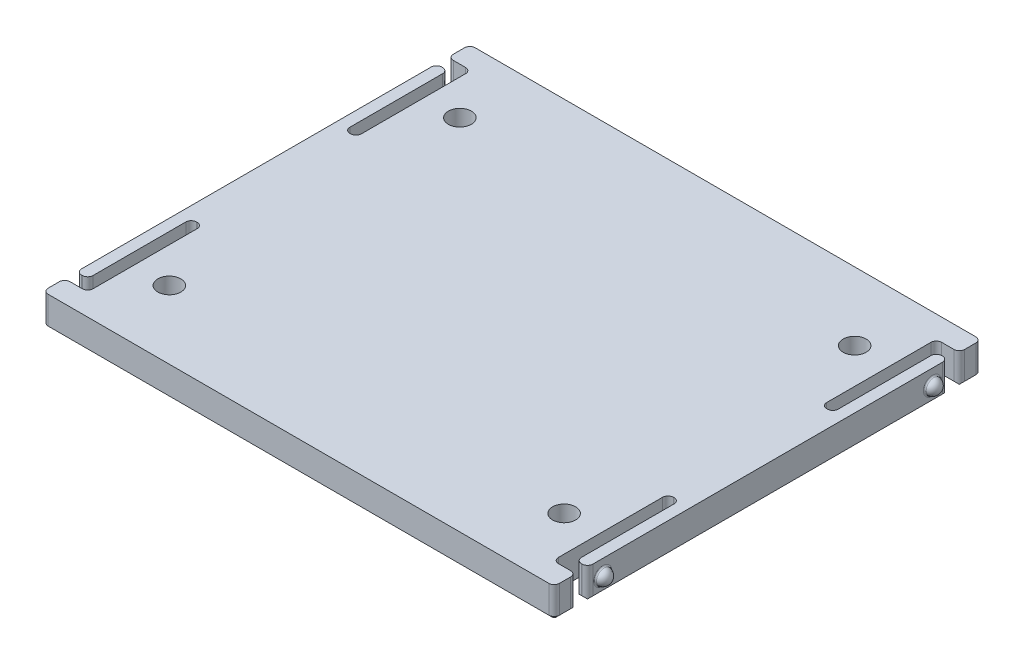
from build123d import *

# Parameters (mm, degrees)
BOSS_EXTRUDE1_DEPTH = 4
SKETCH3_R           = 1.5
CUT_EXTRUDE2_DEPTH  = 5
CHAMFER1_SIZE       = 0.4
FILLET1_R           = 0.7
FILLET2_R           = 0.2


with BuildPart() as part:
    # Sketch1 → Boss-Extrude1 (new body)
    with BuildSketch(Plane(origin=(0, 0, 0), x_dir=(1, 0, 0), z_dir=(0, 1, 0))):
        with BuildLine():
            Line((-33.35, 25), (-30.35, 25))
            Line((-30.35, 25), (-30.35, 10))
            Line((-30.35, 10), (-31.85, 10))
            Line((-31.85, 10), (-31.85, 23.5))
            Line((-31.85, 23.5), (-33.35, 23.5))
            Line((-33.35, 23.5), (-33.35, -23.5))
            Line((-33.35, -23.5), (-31.85, -23.5))
            Line((-31.85, -23.5), (-31.85, -10))
            Line((-31.85, -10), (-30.35, -10))
            Line((-30.35, -10), (-30.35, -25))
            Line((-30.35, -25), (-33.35, -25))
            Line((-33.35, -25), (-33.35, -27.15))
            ThreePointArc((-33.35, -27.15), (-33.144974747, -27.644974747), (-32.65, -27.85))
            Line((-32.65, -27.85), (32.65, -27.85))
            ThreePointArc((32.65, -27.85), (33.144974747, -27.644974747), (33.35, -27.15))
            Line((33.35, -27.15), (33.35, -25))
            Line((33.35, -25), (30.35, -25))
            Line((30.35, -25), (30.35, -10))
            Line((30.35, -10), (31.85, -10))
            Line((31.85, -10), (31.85, -23.5))
            Line((31.85, -23.5), (33.35, -23.5))
            Line((33.35, -23.5), (33.35, 23.5))
            Line((33.35, 23.5), (31.85, 23.5))
            Line((31.85, 23.5), (31.85, 10))
            Line((31.85, 10), (30.35, 10))
            Line((30.35, 10), (30.35, 25))
            Line((30.35, 25), (33.35, 25))
            Line((33.35, 25), (33.35, 27.15))
            ThreePointArc((33.35, 27.15), (33.144974747, 27.644974747), (32.65, 27.85))
            Line((32.65, 27.85), (-32.65, 27.85))
            ThreePointArc((-32.65, 27.85), (-33.144974747, 27.644974747), (-33.35, 27.15))
            Line((-33.35, 27.15), (-33.35, 25))
        make_face()
    extrude(amount=BOSS_EXTRUDE1_DEPTH)

    # Sketch3 → Cut-Extrude2 (cut, through all)
    with BuildSketch(Plane(origin=(0, 4, 0), x_dir=(1, 0, 0), z_dir=(0, 1, 0))):
        with Locations((-25.75, 18.95)):
            Circle(SKETCH3_R)
        with Locations((25.75, 18.95)):
            Circle(SKETCH3_R)
        with Locations((25.75, -18.95)):
            Circle(SKETCH3_R)
        with Locations((-25.75, -18.95)):
            Circle(SKETCH3_R)
    extrude(amount=-CUT_EXTRUDE2_DEPTH, mode=Mode.SUBTRACT)

    # Sketch5 → Revolve1 (revolve)
    with BuildSketch(Plane(origin=(0, 2, 0), x_dir=(1, 0, 0), z_dir=(0, 1, 0))):
        with BuildLine():
            Line((-34.35, 21.5), (-33.35, 21.5))
            Line((-33.35, 21.5), (-33.35, 20.5))
            ThreePointArc((-33.35, 20.5), (-34.057106781, 20.792893219), (-34.35, 21.5))
        make_face()
    revolve1 = revolve(axis=Axis((-34.35, 2, -21.5), (1, 0, 0)))

    # Mirror1: Revolve1 across plane
    add(revolve1.mirror(Plane.XY))

    # Mirror2: Revolve1 across plane
    add(revolve1.mirror(Plane(origin=(0, 0, 0), x_dir=(0, 0, 1), z_dir=(1, 0, 0))))

    # Mirror2 copy 1 sketch → Mirror2 copy 1 (revolve)
    with BuildSketch(Plane(origin=(0, 2, 0), x_dir=(-1, 0, 0), z_dir=(0, 1, 0))):
        with BuildLine():
            Line((-34.35, 21.5), (-33.35, 21.5))
            Line((-33.35, 21.5), (-33.35, 20.5))
            ThreePointArc((-33.35, 20.5), (-34.057106781, 20.792893219), (-34.35, 21.5))
        make_face()
    revolve(axis=Axis((34.35, 2, 21.5), (-1, 0, 0)))

    # Chamfer1
    chamfer1_edges = [part.edges().sort_by_distance(p)[0] for p in [
        (24.25, 0, 18.95),
        (24.25, 0, -18.95),
        (-27.25, 0, -18.95),
        (-33.144974747, 0, -27.644974747),
        (0, 0, -27.85),
        (33.144974747, 0, -27.644974747),
        (33.35, 0, -26.075),
        (31.85, 0, -25),
        (30.35, 0, -17.5),
        (31.1, 0, -10),
        (31.85, 0, -16.75),
        (32.6, 0, -23.5),
        (33.35, 0, 0),
        (32.6, 0, 23.5),
        (31.85, 0, 16.75),
        (31.1, 0, 10),
        (30.35, 0, 17.5),
        (31.85, 0, 25),
        (33.35, 0, 26.075),
        (33.144974747, 0, 27.644974747),
        (0, 0, 27.85),
        (-33.144974747, 0, 27.644974747),
        (-33.35, 0, 26.075),
        (-31.85, 0, 25),
        (-30.35, 0, 17.5),
        (-31.1, 0, 10),
        (-31.85, 0, 16.75),
        (-32.6, 0, 23.5),
        (-33.35, 0, 0),
        (-32.6, 0, -23.5),
        (-31.85, 0, -16.75),
        (-31.1, 0, -10),
        (-30.35, 0, -17.5),
        (-31.85, 0, -25),
        (-33.35, 0, -26.075),
        (-27.25, 0, 18.95),
    ]]
    chamfer(chamfer1_edges, length=CHAMFER1_SIZE)

    # Fillet1
    fillet1_edges = [part.edges().sort_by_distance(p)[0] for p in [
        (33.35, 2.2, -25),
        (30.35, 2.2, -25),
        (30.35, 2.2, -10),
        (31.85, 2.2, -10),
        (31.85, 2.2, -23.5),
        (33.35, 2.2, -23.5),
        (33.35, 2.2, 23.5),
        (31.85, 2.2, 23.5),
        (31.85, 2.2, 10),
        (30.35, 2.2, 10),
        (30.35, 2.2, 25),
        (33.35, 2.2, 25),
        (-33.35, 2.2, 25),
        (-30.35, 2.2, 25),
        (-30.35, 2.2, 10),
        (-31.85, 2.2, 10),
        (-31.85, 2.2, 23.5),
        (-33.35, 2.2, 23.5),
        (-33.35, 2.2, -23.5),
        (-31.85, 2.2, -23.5),
        (-31.85, 2.2, -10),
        (-30.35, 2.2, -10),
        (-30.35, 2.2, -25),
        (-33.35, 2.2, -25),
    ]]
    fillet(fillet1_edges, radius=FILLET1_R)

    # Fillet2
    fillet2_edges = [part.edges().sort_by_distance(p)[0] for p in [
        (-33.35, 2, -22.5),
        (-33.35, 2, 22.5),
        (33.35, 2, 22.5),
        (33.35, 2, -22.5),
    ]]
    fillet(fillet2_edges, radius=FILLET2_R)


solid = part.part
